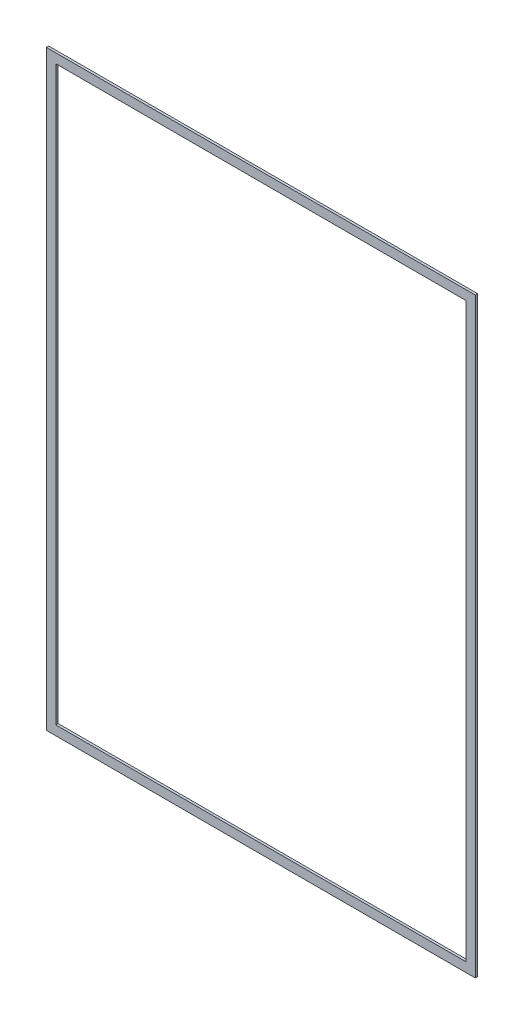
from build123d import *

# Parameters (mm, degrees)
SKETCH1_W           = 578.0532
SKETCH1_H           = 797.0266
SKETCH1_W_2         = 552.6532
SKETCH1_H_2         = 771.6266
BOSS_EXTRUDE1_DEPTH = 3.175


with BuildPart() as part:
    # Sketch1 → Boss-Extrude1 (new body)
    with BuildSketch(Plane.XY):
        Rectangle(SKETCH1_W, SKETCH1_H)
        Rectangle(SKETCH1_W_2, SKETCH1_H_2, mode=Mode.SUBTRACT)
    extrude(amount=BOSS_EXTRUDE1_DEPTH)


solid = part.part
